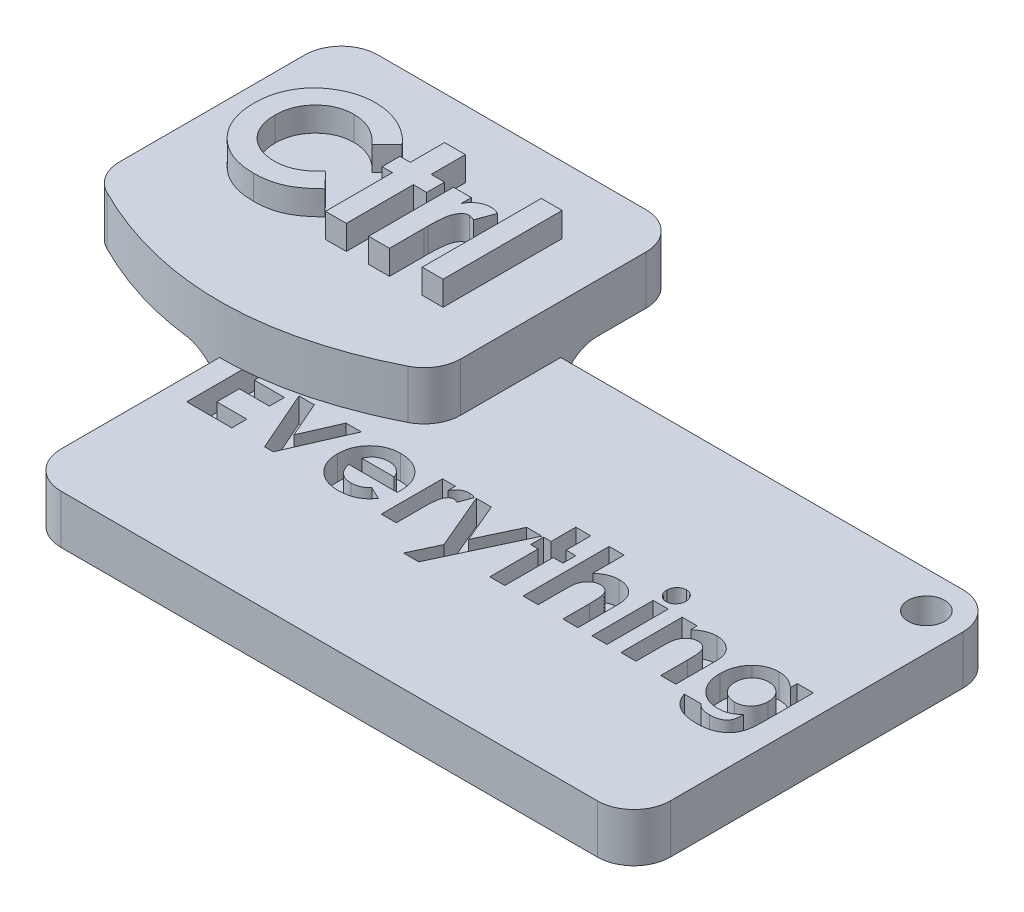
from build123d import *

# Parameters (mm, degrees)
EXTRUDE_1_DEPTH     = 4
SKETCH_2_W          = 1.709615385
SKETCH_2_H          = 9.769230769
EXTRUDE_2_DEPTH     = 2
FILLET_2_R          = 3
SKETCH_3_W          = 50
SKETCH_3_H          = 30
EXTRUDE_3_DEPTH     = 4
FILLET_3_R          = 3
SKETCH_4_W          = 1.234722222
SKETCH_4_H          = 5.027083333
CUT_EXTRUDE_1_DEPTH = 2
SKETCH_5_R          = 1.5
CUT_EXTRUDE_2_DEPTH = 59.617403706


with BuildPart() as part:
    # 草图1 → 凸台-拉伸1 (new body)
    with BuildSketch(Plane(origin=(0, 0, 0), x_dir=(1, 0, 0), z_dir=(0, 1, 0))):
        with BuildLine():
            Line((-14, -10), (-14, 10))
            Line((-14, 10), (14, 10))
            Line((14, 10), (14, -10))
            add(Edge.make_bspline(
                [(-14, -10), (0, -18), (14, -10)],
                knots=[0, 0, 0, 1, 1, 1], degree=2))
        make_face()
    extrude(amount=EXTRUDE_1_DEPTH)

    # 草图2 → 凸台-拉伸2 (add)
    with BuildSketch(Plane(origin=(0, 4, 0), x_dir=(1, 0, 0), z_dir=(0, 1, 0))):
        with BuildLine():
            Line((-1.62616058, 2.607909579), (-2.879751325, 1.409652367))
            add(Edge.make_bspline(
                [(-2.879751325, 1.409652367), (-2.986091104, 1.519607878), (-3.19380601, 1.734385438), (-3.52851289, 2.018731999), (-3.876595859, 2.255696385), (-4.231283657, 2.455266282), (-4.59895609, 2.606255132), (-4.975361862, 2.716283251), (-5.362904436, 2.783363236), (-5.625178343, 2.791038373), (-5.757095075, 2.794898761)],
                knots=[0, 0, 0, 0, 1.115251505, 2.178435587, 3.19620269, 4.182487026, 5.141301733, 6.088180966, 7.038406374, 8, 8, 8, 8], degree=3))
            add(Edge.make_bspline(
                [(-5.757095075, 2.794898761), (-5.867261576, 2.79184892), (-6.08466303, 2.785830394), (-6.403865333, 2.741708661), (-6.709198833, 2.666677735), (-7.001708734, 2.563271219), (-7.280534314, 2.429468677), (-7.546260165, 2.265373667), (-7.798231151, 2.072468201), (-8.033118881, 1.85175038), (-8.247985921, 1.610599575), (-8.437834633, 1.353292241), (-8.596863382, 1.080417855), (-8.72737569, 0.794739889), (-8.829039733, 0.494936082), (-8.901640632, 0.181208276), (-8.943631052, -0.146817156), (-8.949898404, -0.369806401), (-8.953083656, -0.483136094)],
                knots=[0, 0, 0, 0, 1.035432265, 2.043311493, 3.022114605, 3.98653278, 4.95457646, 5.923598177, 6.917315552, 7.932509744, 8.948865224, 9.949768934, 10.933144597, 11.912367597, 12.897413939, 13.903909035, 14.934704909, 16, 16, 16, 16], degree=3))
            add(Edge.make_bspline(
                [(-8.953083656, -0.483136094), (-8.952165703, -0.562678803), (-8.950356398, -0.719459116), (-8.930550354, -0.951380712), (-8.898657954, -1.176399488), (-8.852501749, -1.394174602), (-8.79478296, -1.60489478), (-8.727065679, -1.810377893), (-8.642115346, -2.007784627), (-8.547819195, -2.199407735), (-8.438153857, -2.380018539), (-8.319914393, -2.55224593), (-8.191702999, -2.715245666), (-8.052689241, -2.8683514), (-7.900916675, -3.009170432), (-7.74030806, -3.141937357), (-7.56815415, -3.263328571), (-7.388031019, -3.376390518), (-7.198382631, -3.474608393), (-7.004354585, -3.563574814), (-6.803005025, -3.635828774), (-6.596785505, -3.694072058), (-6.386432978, -3.743599272), (-6.169890003, -3.7740947), (-5.949033735, -3.797188531), (-5.799771969, -3.79861444), (-5.724658176, -3.799332008)],
                knots=[0, 0, 0, 0, 1.103660481, 2.175337485, 3.227646561, 4.255952547, 5.262355991, 6.258840057, 7.255597736, 8.242457506, 9.22035537, 10.185017736, 11.140346927, 12.096287581, 13.051739095, 14.01125915, 14.986044842, 15.97314143, 16.960198552, 17.947847494, 18.933482797, 19.925264591, 20.920966487, 21.929612487, 22.958107872, 24, 24, 24, 24], degree=3))
            add(Edge.make_bspline(
                [(-5.724658176, -3.799332008), (-5.597252274, -3.795646753), (-5.346932807, -3.788406186), (-4.979552998, -3.731785974), (-4.629476639, -3.638648931), (-4.349767303, -3.528659494), (-4.130622427, -3.420043497), (-3.963790673, -3.319579049), (-3.791273636, -3.207198534), (-3.615936677, -3.078660588), (-3.435807602, -2.93550772), (-3.254066107, -2.774604614), (-3.066059575, -2.601249578), (-2.94289836, -2.477522683), (-2.879751325, -2.414085614)],
                knots=[0, 0, 0, 0, 1.404581149, 2.759636711, 4.088442092, 5.392261763, 6.066678138, 6.783632037, 7.538459478, 8.336747902, 9.180226004, 10.074962426, 11.012997595, 12, 12, 12, 12], degree=3))
            Line((-2.879751325, -2.414085614), (-1.664321637, -3.690572993))
            add(Edge.make_bspline(
                [(-1.664321637, -3.690572993), (-1.749759802, -3.773060859), (-1.916516828, -3.934059533), (-2.168065173, -4.162662626), (-2.419296935, -4.368087918), (-2.664142876, -4.557791447), (-2.906613831, -4.726246688), (-3.146684084, -4.873621879), (-3.381635935, -5.003644352), (-3.616348235, -5.114121342), (-3.852281486, -5.207927781), (-4.095029075, -5.288688967), (-4.345333104, -5.357010026), (-4.604722317, -5.412136147), (-4.870777289, -5.456339854), (-5.14598794, -5.486177101), (-5.4286093, -5.506235689), (-5.620315747, -5.50803812), (-5.717025964, -5.508947393)],
                knots=[0, 0, 0, 0, 1.244526981, 2.429050516, 3.560637417, 4.644440555, 5.67424972, 6.652764056, 7.595344123, 8.486817594, 9.369275933, 10.254498637, 11.166417451, 12.086725134, 13.032340136, 13.991389299, 14.986715468, 16, 16, 16, 16], degree=3))
            add(Edge.make_bspline(
                [(-5.717025964, -5.508947393), (-5.894670654, -5.504418875), (-6.242271932, -5.495557825), (-6.751672543, -5.429903446), (-7.235589449, -5.319835035), (-7.695199929, -5.164167943), (-8.130357839, -4.965310528), (-8.540951851, -4.721520675), (-8.92632018, -4.433446096), (-9.283349807, -4.104463303), (-9.606300097, -3.741129426), (-9.891750754, -3.351008519), (-10.127875548, -2.932183281), (-10.323935052, -2.490841099), (-10.477251006, -2.024967957), (-10.585159446, -1.534059921), (-10.651705794, -1.018590995), (-10.658986059, -0.666513835), (-10.662699041, -0.4869522)],
                knots=[0, 0, 0, 0, 1.078019885, 2.10938526, 3.111377082, 4.085535484, 5.04941344, 6.010039228, 6.978205633, 7.964457913, 8.951525778, 9.924444315, 10.892603023, 11.863865945, 12.85144698, 13.863884204, 14.910567087, 16, 16, 16, 16], degree=3))
            add(Edge.make_bspline(
                [(-10.662699041, -0.4869522), (-10.661130115, -0.369843634), (-10.658020886, -0.137763077), (-10.625342605, 0.204110385), (-10.579787181, 0.537375859), (-10.507517643, 0.858572945), (-10.420403842, 1.172028759), (-10.312066386, 1.474336404), (-10.182678304, 1.766364741), (-10.036410079, 2.048602644), (-9.870938299, 2.319201152), (-9.686088156, 2.575835398), (-9.486618412, 2.82048655), (-9.267736135, 3.049908857), (-9.032621971, 3.266116692), (-8.780214407, 3.467938382), (-8.512031548, 3.658268278), (-8.227347523, 3.832198235), (-7.931692984, 3.989527126), (-7.628796912, 4.128297927), (-7.319403488, 4.24427836), (-7.004820856, 4.340479851), (-6.683719908, 4.412287461), (-6.35839258, 4.466643506), (-6.026070729, 4.497028883), (-5.802945395, 4.502003163), (-5.690313224, 4.504514146)],
                knots=[0, 0, 0, 0, 1.071919942, 2.124283339, 3.142214191, 4.149696895, 5.136002878, 6.119640489, 7.086990633, 8.058538607, 9.028339693, 9.988281803, 10.952401235, 11.916291999, 12.888973767, 13.874849856, 14.873389453, 15.898127285, 16.927174885, 17.938320013, 18.946391617, 19.950418109, 20.947802303, 21.956882652, 22.968648068, 24, 24, 24, 24], degree=3))
            add(Edge.make_bspline(
                [(-5.690313224, 4.504514146), (-5.594226433, 4.503074788), (-5.403051886, 4.500211037), (-5.118360906, 4.476338555), (-4.83594675, 4.438847064), (-4.556820549, 4.382280388), (-4.278985707, 4.315128596), (-4.006093285, 4.227202587), (-3.733838257, 4.12919248), (-3.466490538, 4.01204141), (-3.203676952, 3.884160434), (-2.951554319, 3.739074824), (-2.705889525, 3.585712984), (-2.472126354, 3.41499829), (-2.245885917, 3.233122881), (-2.028351247, 3.039238206), (-1.821431337, 2.830111638), (-1.69157989, 2.682351373), (-1.62616058, 2.607909579)],
                knots=[0, 0, 0, 0, 0.996412454, 1.982464992, 2.961075852, 3.949442424, 4.934965278, 5.923860011, 6.921385422, 7.934793307, 8.949617135, 9.951082467, 10.950285876, 11.951772932, 12.951063433, 13.960125323, 14.972308753, 16, 16, 16, 16], degree=3))
        make_face()
        Polygon((-0.03866058, 4.504514146), (1.670954805, 4.504514146), (1.670954805, 1.6958603), (2.769993267, 1.6958603), (2.769993267, 0.230475684), (1.670954805, 0.230475684), (1.670954805, -5.264716623), (-0.03866058, -5.264716623), (-0.03866058, 0.230475684), (-0.893468272, 0.230475684), (-0.893468272, 1.6958603), (-0.03866058, 1.6958603), align=None)
        with BuildLine():
            Line((3.502685574, 1.6958603), (4.96807019, 1.6958603))
            Line((4.96807019, 1.6958603), (4.96807019, 0.839144555))
            add(Edge.make_bspline(
                [(4.96807019, 0.839144555), (5.009523107, 0.915281119), (5.090544555, 1.064093192), (5.239387748, 1.26384393), (5.410384838, 1.432068428), (5.597391369, 1.572285256), (5.800974121, 1.681570505), (6.015681512, 1.759450022), (6.239676723, 1.810060917), (6.392478663, 1.815318432), (6.46970781, 1.817975684)],
                knots=[0, 0, 0, 0, 1.09866127, 2.147379032, 3.14564304, 4.131443017, 5.102343063, 6.064490016, 7.021754664, 8, 8, 8, 8], degree=3))
            add(Edge.make_bspline(
                [(6.46970781, 1.817975684), (6.525785807, 1.815349763), (6.639980634, 1.810002451), (6.814029619, 1.77891844), (6.990589825, 1.722712639), (7.106781655, 1.672106785), (7.166147113, 1.646250925)],
                knots=[0, 0, 0, 0, 0.931404136, 1.896671404, 2.925354185, 4, 4, 4, 4], degree=3))
            Line((7.166147113, 1.646250925), (6.635708411, 0.198038785))
            add(Edge.make_bspline(
                [(6.635708411, 0.198038785), (6.588294766, 0.220946766), (6.499175364, 0.264004952), (6.369789468, 0.314818047), (6.252366403, 0.345821714), (6.177922334, 0.350447733), (6.143430767, 0.352591069)],
                knots=[0, 0, 0, 0, 1.214386998, 2.282580073, 3.20428172, 4, 4, 4, 4], degree=3))
            add(Edge.make_bspline(
                [(6.143430767, 0.352591069), (6.110864019, 0.351170781), (6.046799615, 0.348376831), (5.952242348, 0.324433625), (5.863189093, 0.283144308), (5.775348378, 0.230248596), (5.695649862, 0.156719599), (5.616000574, 0.07159673), (5.545809357, -0.033498774), (5.471737266, -0.150475407), (5.40866753, -0.293654701), (5.354587172, -0.464581272), (5.30640114, -0.665232859), (5.273242571, -0.896674822), (5.241193483, -1.156667561), (5.222117079, -1.447119392), (5.207899193, -1.767111876), (5.207029865, -1.990478179), (5.2065768, -2.106889099)],
                knots=[0, 0, 0, 0, 0.544232178, 1.070598461, 1.618251235, 2.182094276, 2.777567932, 3.425210017, 4.127676488, 4.886675562, 5.738955394, 6.734782583, 7.883056018, 9.186093582, 10.642914445, 12.264202625, 14.053029461, 16, 16, 16, 16], degree=3))
            Line((5.2065768, -2.106889099), (5.212300959, -2.446522513))
            Line((5.212300959, -2.446522513), (5.212300959, -5.264716623))
            Line((5.212300959, -5.264716623), (3.502685574, -5.264716623))
            Line((3.502685574, -5.264716623), (3.502685574, 1.6958603))
        make_face()
        with Locations((8.753647113, -0.380101238)):
            Rectangle(SKETCH_2_W, SKETCH_2_H)
    extrude(amount=EXTRUDE_2_DEPTH)

    # 圆角2
    fillet_2_edges = [part.edges().sort_by_distance(p)[0] for p in [
        (14, 2, -10),
        (14, 2, 10),
        (-14, 2, 10),
        (-14, 2, -10),
    ]]
    fillet(fillet_2_edges, radius=FILLET_2_R)

    # 草图3 → 凸台-拉伸3 (add)
    with BuildSketch(Plane.XZ):
        with Locations((25, 15)):
            Rectangle(SKETCH_3_W, SKETCH_3_H)
    extrude(amount=EXTRUDE_3_DEPTH)

    # 圆角3
    fillet_3_edges = [part.edges().sort_by_distance(p)[0] for p in [
        (0, 0, 7),
        (7, 0, 0),
        (0, -2, 30),
        (50, -2, 30),
        (50, -2, 0),
    ]]
    fillet(fillet_3_edges, radius=FILLET_3_R)

    # 草图4 → 切除-拉伸1 (cut)
    with BuildSketch(Plane(origin=(0, 0, 0), x_dir=(1, 0, 0), z_dir=(0, 1, 0))):
        Polygon((1.80262527, -11.616395699), (5.506791936, -11.616395699), (5.506791936, -12.851117921), (3.037347492, -12.851117921), (3.037347492, -14.174034587), (5.506791936, -14.174034587), (5.506791936, -15.40875681), (3.037347492, -15.40875681), (3.037347492, -17.260840143), (5.506791936, -17.260840143), (5.506791936, -18.495562365), (1.80262527, -18.495562365), align=None)
        Polygon((5.991861381, -13.468479032), (7.248632214, -13.468479032), (8.54950027, -16.435395265), (9.850368325, -13.468479032), (11.107139158, -13.468479032), (8.905034124, -18.495562365), (8.193966415, -18.495562365), align=None)
        with BuildLine():
            Line((16.879741155, -16.290701254), (12.91512527, -16.290701254))
            add(Edge.make_bspline(
                [(12.91512527, -16.290701254), (12.923208801, -16.336767841), (12.939093579, -16.42729232), (12.973587938, -16.55878698), (13.017607913, -16.682705329), (13.070363081, -16.799213014), (13.130963991, -16.908925966), (13.201649931, -17.011329588), (13.281524316, -17.106333431), (13.370125332, -17.193524598), (13.465976161, -17.271649773), (13.568611964, -17.340092365), (13.678138652, -17.396211104), (13.793300544, -17.443513377), (13.914958165, -17.48098157), (14.043290563, -17.50682267), (14.177957549, -17.522087102), (14.269696814, -17.524294928), (14.316590113, -17.525423476)],
                knots=[0, 0, 0, 0, 1.091296461, 2.144483647, 3.168565212, 4.157007626, 5.126487748, 6.090021542, 7.05641414, 8.019231907, 8.98705074, 9.938580405, 10.892824166, 11.854447369, 12.841318655, 13.858982407, 14.905600794, 16, 16, 16, 16], degree=3))
            add(Edge.make_bspline(
                [(14.316590113, -17.525423476), (14.373193509, -17.523929092), (14.484662264, -17.520986209), (14.64796482, -17.49488721), (14.80590218, -17.455465818), (14.9569797, -17.396842899), (15.102947374, -17.32386767), (15.241402129, -17.232949515), (15.374740505, -17.126745358), (15.456092628, -17.044883235), (15.497568846, -17.003147001)],
                knots=[0, 0, 0, 0, 1.021034703, 2.010718019, 2.977989445, 3.954245119, 4.929443971, 5.918328161, 6.938689359, 8, 8, 8, 8], degree=3))
            Line((15.497568846, -17.003147001), (16.531097492, -17.495106636))
            add(Edge.make_bspline(
                [(16.531097492, -17.495106636), (16.498557446, -17.540071986), (16.434080541, -17.629169173), (16.328824157, -17.754551926), (16.218982419, -17.871539121), (16.104473405, -17.979361315), (15.985151891, -18.077711259), (15.8613498, -18.167787031), (15.731257814, -18.247170134), (15.5974771, -18.319701074), (15.457242163, -18.381881512), (15.310941094, -18.434906795), (15.159193561, -18.4828412), (15.00008332, -18.51936459), (14.834935282, -18.548276208), (14.663354378, -18.568807287), (14.485363224, -18.581488351), (14.364383673, -18.582991675), (14.302809731, -18.58375681)],
                knots=[0, 0, 0, 0, 1.028154879, 2.037251081, 3.030720504, 4.000128189, 4.949298328, 5.894184978, 6.834267904, 7.770992897, 8.712077017, 9.673380525, 10.653304757, 11.658697181, 12.695551717, 13.758623199, 14.859225354, 16, 16, 16, 16], degree=3))
            add(Edge.make_bspline(
                [(14.302809731, -18.58375681), (14.208079233, -18.58182554), (14.022555013, -18.578043259), (13.751192303, -18.542938281), (13.493472993, -18.484730444), (13.248669375, -18.405605829), (13.017839652, -18.301136549), (12.800869587, -18.173361953), (12.595591338, -18.024731737), (12.408277302, -17.852126548), (12.237628689, -17.664256061), (12.087741557, -17.462495986), (11.96231814, -17.248255946), (11.859317907, -17.022953826), (11.779262548, -16.786012941), (11.721547277, -16.537329894), (11.686167125, -16.277023461), (11.682345893, -16.099725722), (11.680403047, -16.009581462)],
                knots=[0, 0, 0, 0, 1.103565453, 2.161269334, 3.182010356, 4.179077853, 5.15417608, 6.128274628, 7.109042802, 8.101804412, 9.090965879, 10.063106201, 11.02526161, 11.978650795, 12.945248442, 13.93468508, 14.949922959, 16, 16, 16, 16], degree=3))
            add(Edge.make_bspline(
                [(11.680403047, -16.009581462), (11.682365015, -15.917146521), (11.686225097, -15.735284926), (11.721242654, -15.468967899), (11.779422111, -15.214865433), (11.859711649, -14.972627605), (11.961149356, -14.741496796), (12.088168571, -14.523495126), (12.237554308, -14.31786363), (12.407588163, -14.125564274), (12.595695719, -13.951993096), (12.79557777, -13.79730649), (13.009480194, -13.668411342), (13.234983572, -13.564264142), (13.470645502, -13.479647171), (13.719189907, -13.423341644), (13.978725743, -13.385535853), (14.156138725, -13.382054175), (14.246310165, -13.380284587)],
                knots=[0, 0, 0, 0, 1.079208495, 2.12329425, 3.130605359, 4.119693003, 5.099659317, 6.073216462, 7.060498243, 8.06384408, 9.066070512, 10.045757761, 11.010926815, 11.975797609, 12.942977511, 13.929384301, 14.947594487, 16, 16, 16, 16], degree=3))
            add(Edge.make_bspline(
                [(14.246310165, -13.380284587), (14.341494487, -13.38224582), (14.528379092, -13.386096497), (14.80163176, -13.42091643), (15.061062295, -13.479479212), (15.307776015, -13.557919651), (15.538622287, -13.665027935), (15.758673502, -13.7896582), (15.962651583, -13.941501171), (16.152730721, -14.113261686), (16.324315991, -14.303824025), (16.474300528, -14.510833091), (16.60191891, -14.732268596), (16.705354874, -14.969028508), (16.785328031, -15.220402051), (16.843096728, -15.486062768), (16.878207014, -15.767021103), (16.881957141, -15.959409378), (16.88387527, -16.057812799)],
                knots=[0, 0, 0, 0, 1.080001299, 2.120471247, 3.119684163, 4.095710327, 5.052285597, 6.002875087, 6.961153713, 7.931888285, 8.906493152, 9.865905668, 10.82813294, 11.801621613, 12.7925306, 13.817193356, 14.883530496, 16, 16, 16, 16], degree=3))
            Line((16.88387527, -16.057812799), (16.879741155, -16.290701254))
        make_face()
        with BuildLine():
            add(Edge.make_bspline(
                [(15.649153047, -15.320562365), (15.625853084, -15.257685202), (15.579526687, -15.132669022), (15.474877284, -14.960177198), (15.336010874, -14.810792273), (15.174499278, -14.678540614), (14.989962165, -14.571196907), (14.788214625, -14.493476577), (14.571806707, -14.446874492), (14.42292972, -14.441408886), (14.346906954, -14.438617921)],
                knots=[0, 0, 0, 0, 0.954238005, 1.897273737, 2.851915805, 3.847685534, 4.862635127, 5.880135777, 6.917509367, 8, 8, 8, 8], degree=3))
            add(Edge.make_bspline(
                [(14.346906954, -14.438617921), (14.263877715, -14.441298983), (14.101572841, -14.4465399), (13.867459112, -14.502278983), (13.646625489, -14.585467899), (13.516434501, -14.671237438), (13.451182127, -14.71422556)],
                knots=[0, 0, 0, 0, 1.044195649, 2.041185066, 3.018232172, 4, 4, 4, 4], degree=3))
            add(Edge.make_bspline(
                [(13.451182127, -14.71422556), (13.41046952, -14.746966254), (13.323672321, -14.816767742), (13.21094855, -14.956015083), (13.099914698, -15.124612354), (13.036785831, -15.252673892), (13.003319714, -15.320562365)],
                knots=[0, 0, 0, 0, 0.82159062, 1.751589201, 2.808063854, 4, 4, 4, 4], degree=3))
            Line((13.003319714, -15.320562365), (15.649153047, -15.320562365))
        make_face(mode=Mode.SUBTRACT)
        with BuildLine():
            Line((17.765819714, -13.468479032), (18.824153047, -13.468479032))
            Line((18.824153047, -13.468479032), (18.824153047, -14.087218181))
            add(Edge.make_bspline(
                [(18.824153047, -14.087218181), (18.854091266, -14.032230663), (18.912606755, -13.924755277), (19.020104617, -13.780490855), (19.143602515, -13.658995383), (19.278662788, -13.557727675), (19.425694776, -13.478799439), (19.580761225, -13.422553121), (19.742535544, -13.386000809), (19.8528925, -13.382203714), (19.908669106, -13.380284587)],
                knots=[0, 0, 0, 0, 1.09866127, 2.147379032, 3.14564304, 4.131443017, 5.102343063, 6.064490016, 7.021754664, 8, 8, 8, 8], degree=3))
            add(Edge.make_bspline(
                [(19.908669106, -13.380284587), (19.949169882, -13.382181086), (20.031643924, -13.386043034), (20.157345968, -13.408492597), (20.284861673, -13.449085676), (20.368777995, -13.485634348), (20.411653047, -13.504308025)],
                knots=[0, 0, 0, 0, 0.931404136, 1.896671404, 2.925354185, 4, 4, 4, 4], degree=3))
            Line((20.411653047, -13.504308025), (20.028558429, -14.550239015))
            add(Edge.make_bspline(
                [(20.028558429, -14.550239015), (19.994315241, -14.533694362), (19.929951229, -14.502596783), (19.83650586, -14.465898437), (19.751700312, -14.443506899), (19.697935152, -14.440165886), (19.673024575, -14.438617921)],
                knots=[0, 0, 0, 0, 1.214386998, 2.282580073, 3.20428172, 4, 4, 4, 4], degree=3))
            add(Edge.make_bspline(
                [(19.673024575, -14.438617921), (19.649504146, -14.439643684), (19.60323541, -14.441661537), (19.534944051, -14.458953853), (19.470627811, -14.488773915), (19.407187294, -14.526976374), (19.349627255, -14.580080649), (19.292102769, -14.641558277), (19.241409112, -14.717460585), (19.187912603, -14.801943709), (19.142362237, -14.905350977), (19.103304202, -15.028797945), (19.068503178, -15.17371298), (19.044555323, -15.340865509), (19.021408759, -15.528638043), (19.007631356, -15.738408809), (18.997362883, -15.969514492), (18.996735035, -16.1308346), (18.996407822, -16.214909153)],
                knots=[0, 0, 0, 0, 0.544232178, 1.070598461, 1.618251235, 2.182094276, 2.777567932, 3.425210017, 4.127676488, 4.886675562, 5.738955394, 6.734782583, 7.883056018, 9.186093582, 10.642914445, 12.264202625, 14.053029461, 16, 16, 16, 16], degree=3))
            Line((18.996407822, -16.214909153), (19.000541936, -16.460199952))
            Line((19.000541936, -16.460199952), (19.000541936, -18.495562365))
            Line((19.000541936, -18.495562365), (17.765819714, -18.495562365))
            Line((17.765819714, -18.495562365), (17.765819714, -13.468479032))
        make_face()
        Polygon((20.541188638, -13.468479032), (21.777288898, -13.468479032), (23.14981494, -16.702734674), (24.66841303, -13.468479032), (25.923805825, -13.468479032), (22.692306259, -20.347645699), (21.436913464, -20.347645699), (22.499380912, -18.086285021), align=None)
        Polygon((26.673458603, -11.44000681), (27.908180825, -11.44000681), (27.908180825, -13.468479032), (28.701930825, -13.468479032), (28.701930825, -14.526812365), (27.908180825, -14.526812365), (27.908180825, -18.495562365), (26.673458603, -18.495562365), (26.673458603, -14.526812365), (26.056097492, -14.526812365), (26.056097492, -13.468479032), (26.673458603, -13.468479032), align=None)
        with BuildLine():
            Line((29.407486381, -11.44000681), (30.642208603, -11.44000681))
            Line((30.642208603, -11.44000681), (30.642208603, -14.012804119))
            add(Edge.make_bspline(
                [(30.642208603, -14.012804119), (30.704404178, -13.962223003), (30.825634132, -13.863631644), (31.015847904, -13.735190497), (31.205668242, -13.625586015), (31.397109419, -13.536759076), (31.589340895, -13.467150606), (31.782694622, -13.417785441), (31.977356738, -13.385397535), (32.107855311, -13.381990721), (32.173209037, -13.380284587)],
                knots=[0, 0, 0, 0, 1.13710654, 2.216417683, 3.252896077, 4.244436563, 5.207303112, 6.149540546, 7.073289332, 8, 8, 8, 8], degree=3))
            add(Edge.make_bspline(
                [(32.173209037, -13.380284587), (32.235748166, -13.381944012), (32.358517729, -13.385201601), (32.53862812, -13.408731629), (32.711137907, -13.44922074), (32.876472059, -13.504880044), (33.033493109, -13.579733608), (33.18424294, -13.667415107), (33.32692969, -13.772465743), (33.41374645, -13.853443898), (33.457540634, -13.894292834)],
                knots=[0, 0, 0, 0, 1.056403236, 2.073808271, 3.062028718, 4.046096703, 5.014652014, 5.995532726, 6.988858718, 8, 8, 8, 8], degree=3))
            add(Edge.make_bspline(
                [(33.457540634, -13.894292834), (33.49350722, -13.932462423), (33.565962232, -14.009355405), (33.656203016, -14.141917129), (33.734125032, -14.286309742), (33.797620365, -14.443890089), (33.844842821, -14.614731523), (33.881402578, -14.797426628), (33.901620901, -14.993970225), (33.904116122, -15.129430514), (33.905403047, -15.199295004)],
                knots=[0, 0, 0, 0, 0.887296576, 1.787466942, 2.706642908, 3.663267187, 4.658426068, 5.705361056, 6.816525637, 8, 8, 8, 8], degree=3))
            Line((33.905403047, -15.199295004), (33.905403047, -18.495562365))
            Line((33.905403047, -18.495562365), (32.670680825, -18.495562365))
            Line((32.670680825, -18.495562365), (32.670680825, -16.309993789))
            add(Edge.make_bspline(
                [(32.670680825, -16.309993789), (32.670440916, -16.24063044), (32.669981705, -16.107861835), (32.665857982, -15.917202633), (32.659123813, -15.743996037), (32.64991453, -15.588189703), (32.637056358, -15.450434772), (32.624409442, -15.329743869), (32.606662856, -15.226695509), (32.580089593, -15.114723672), (32.536843957, -14.994960757), (32.474001009, -14.867298637), (32.390060098, -14.76193815), (32.292919252, -14.675042164), (32.180601727, -14.60871986), (32.057128381, -14.559735358), (31.920388368, -14.532187685), (31.825606345, -14.528650938), (31.776334037, -14.526812365)],
                knots=[0, 0, 0, 0, 1.461461505, 2.797388094, 4.017818807, 5.113567707, 6.085313608, 6.932873269, 7.669572396, 8.286941306, 9.355291607, 10.346554054, 11.270113241, 12.175128673, 13.078071705, 14.003657132, 14.962203834, 16, 16, 16, 16], degree=3))
            add(Edge.make_bspline(
                [(31.776334037, -14.526812365), (31.712146817, -14.529321655), (31.586428912, -14.534236382), (31.406143874, -14.584827619), (31.239854643, -14.664793491), (31.089501972, -14.77562259), (30.958485574, -14.914440452), (30.848714052, -15.077148849), (30.758926956, -15.262120344), (30.720119358, -15.397004757), (30.700086207, -15.466634414)],
                knots=[0, 0, 0, 0, 0.993549393, 1.945978497, 2.879753144, 3.843180486, 4.826017097, 5.826060929, 6.877775219, 8, 8, 8, 8], degree=3))
            add(Edge.make_bspline(
                [(30.700086207, -15.466634414), (30.69509791, -15.488155928), (30.68372296, -15.537232022), (30.675011808, -15.620964267), (30.662084596, -15.722182204), (30.657600354, -15.841492385), (30.649200306, -15.978710786), (30.646179318, -16.134059417), (30.643137951, -16.307684328), (30.642528344, -16.429421379), (30.642208603, -16.493272869)],
                knots=[0, 0, 0, 0, 0.514379255, 1.17295301, 1.959069106, 2.891908278, 3.953016936, 5.163065833, 6.51201855, 8, 8, 8, 8], degree=3))
            Line((30.642208603, -16.493272869), (30.642208603, -18.495562365))
            Line((30.642208603, -18.495562365), (29.407486381, -18.495562365))
            Line((29.407486381, -18.495562365), (29.407486381, -11.44000681))
        make_face()
        with BuildLine():
            add(Edge.make_bspline(
                [(35.66653586, -11.351812365), (35.719752379, -11.354423369), (35.824248141, -11.359550327), (35.973952541, -11.409526758), (36.11135084, -11.487963275), (36.232814746, -11.595580044), (36.333837066, -11.724094151), (36.41102187, -11.867974238), (36.454018309, -12.02738874), (36.459989878, -12.137510611), (36.463041936, -12.193793702)],
                knots=[0, 0, 0, 0, 0.989868614, 1.943702388, 2.910836514, 3.924849579, 4.949916355, 5.946401046, 6.950409252, 8, 8, 8, 8], degree=3))
            add(Edge.make_bspline(
                [(36.463041936, -12.193793702), (36.460099075, -12.249662018), (36.454364771, -12.358524091), (36.41003228, -12.515774467), (36.335945406, -12.659584671), (36.234104869, -12.786190105), (36.11395779, -12.892073643), (35.979561749, -12.971934127), (35.831291952, -13.019130381), (35.728417648, -13.024685924), (35.676182127, -13.02750681)],
                knots=[0, 0, 0, 0, 1.05296456, 2.051751585, 3.055639087, 4.085634717, 5.099016424, 6.062201612, 7.016062274, 8, 8, 8, 8], degree=3))
            add(Edge.make_bspline(
                [(35.676182127, -13.02750681), (35.622501072, -13.02490514), (35.517096201, -13.019796658), (35.366163917, -12.969703293), (35.226933076, -12.891884515), (35.105996079, -12.782068968), (35.003816828, -12.652641671), (34.930003487, -12.505411931), (34.883831416, -12.344907356), (34.878350832, -12.233154506), (34.875541936, -12.175879206)],
                knots=[0, 0, 0, 0, 0.989065327, 1.942068821, 2.907541208, 3.917690034, 4.939857478, 5.938239964, 6.943311734, 8, 8, 8, 8], degree=3))
            add(Edge.make_bspline(
                [(34.875541936, -12.175879206), (34.878598783, -12.120959567), (34.884603516, -12.013077866), (34.927857509, -11.857207616), (35.003272468, -11.715746378), (35.103567114, -11.589584842), (35.223964158, -11.48397553), (35.361279975, -11.407921182), (35.509976858, -11.360008919), (35.613810677, -11.354572761), (35.66653586, -11.351812365)],
                knots=[0, 0, 0, 0, 1.038616768, 2.040212704, 3.031499824, 4.052181184, 5.074969369, 6.039807101, 7.004644834, 8, 8, 8, 8], degree=3))
        make_face()
        with Locations((35.669291936, -15.982020699)):
            Rectangle(SKETCH_4_W, SKETCH_4_H)
        with BuildLine():
            Line((37.433180825, -13.468479032), (38.667903047, -13.468479032))
            Line((38.667903047, -13.468479032), (38.667903047, -14.000401775))
            add(Edge.make_bspline(
                [(38.667903047, -14.000401775), (38.738343338, -13.945611866), (38.872968427, -13.840897699), (39.077621806, -13.707386603), (39.270789257, -13.598113132), (39.456776691, -13.514994138), (39.639083465, -13.455193596), (39.820662169, -13.412230474), (40.004216878, -13.384720006), (40.127610197, -13.381762267), (40.189257214, -13.380284587)],
                knots=[0, 0, 0, 0, 1.276643801, 2.439914479, 3.493451431, 4.44993799, 5.350072675, 6.235028322, 7.118224225, 8, 8, 8, 8], degree=3))
            add(Edge.make_bspline(
                [(40.189257214, -13.380284587), (40.251789817, -13.381973269), (40.374546569, -13.385288293), (40.555299122, -13.408474201), (40.727990633, -13.450703084), (40.894562875, -13.506771619), (41.053320427, -13.58077887), (41.206208168, -13.668650473), (41.349942121, -13.775684031), (41.438459853, -13.85719565), (41.483235079, -13.898426949)],
                knots=[0, 0, 0, 0, 1.048836932, 2.058954983, 3.049370783, 4.026390553, 5.001981509, 5.982488534, 6.97947532, 8, 8, 8, 8], degree=3))
            add(Edge.make_bspline(
                [(41.483235079, -13.898426949), (41.519146457, -13.936636306), (41.591232043, -14.013334668), (41.681942696, -14.144585209), (41.75978264, -14.287672322), (41.823561658, -14.444246564), (41.870691782, -14.615168209), (41.90694963, -14.798372767), (41.927294541, -14.994886049), (41.929806216, -15.129888819), (41.931097492, -15.199295004)],
                knots=[0, 0, 0, 0, 0.889584746, 1.785680191, 2.700364693, 3.65222533, 4.649950538, 5.707241244, 6.821271309, 8, 8, 8, 8], degree=3))
            Line((41.931097492, -15.199295004), (41.931097492, -18.495562365))
            Line((41.931097492, -18.495562365), (40.69637527, -18.495562365))
            Line((40.69637527, -18.495562365), (40.69637527, -16.312749865))
            add(Edge.make_bspline(
                [(40.69637527, -16.312749865), (40.696114153, -16.241550324), (40.695613772, -16.105109619), (40.691771951, -15.909842464), (40.684270478, -15.733490866), (40.677433081, -15.575733738), (40.664008553, -15.437131225), (40.651902096, -15.316805866), (40.633325912, -15.215849263), (40.609155283, -15.107255288), (40.566947412, -14.99098558), (40.50142175, -14.868476234), (40.418293259, -14.764401813), (40.320957238, -14.678032705), (40.209521188, -14.609706818), (40.08533165, -14.5616353), (39.94905443, -14.53167595), (39.854098064, -14.528474808), (39.804784558, -14.526812365)],
                knots=[0, 0, 0, 0, 1.49886392, 2.872294502, 4.110984203, 5.214877267, 6.195405875, 7.042225351, 7.75923308, 8.355011229, 9.382752534, 10.352059385, 11.267231453, 12.171456522, 13.078624015, 14.003401117, 14.963110155, 16, 16, 16, 16], degree=3))
            add(Edge.make_bspline(
                [(39.804784558, -14.526812365), (39.740650269, -14.530064632), (39.615191131, -14.536426699), (39.433739588, -14.584402484), (39.267079368, -14.665995172), (39.116572224, -14.778903045), (38.98365161, -14.918301806), (38.874174665, -15.08455082), (38.78438108, -15.273637675), (38.745768504, -15.411701793), (38.725780651, -15.483170872)],
                knots=[0, 0, 0, 0, 0.984188326, 1.925263693, 2.85911992, 3.81709677, 4.80007086, 5.801799564, 6.862098548, 8, 8, 8, 8], degree=3))
            add(Edge.make_bspline(
                [(38.725780651, -15.483170872), (38.720812876, -15.505616215), (38.709733738, -15.555673843), (38.700622548, -15.640240734), (38.687948222, -15.740571162), (38.683199464, -15.858480826), (38.674941896, -15.993411708), (38.671887852, -16.145542319), (38.668828344, -16.314574356), (38.668221698, -16.432636812), (38.667903047, -16.494650907)],
                knots=[0, 0, 0, 0, 0.543362196, 1.211806945, 2.009705693, 2.934833164, 4.000995085, 5.207458376, 6.533175157, 8, 8, 8, 8], degree=3))
            Line((38.667903047, -16.494650907), (38.667903047, -18.495562365))
            Line((38.667903047, -18.495562365), (37.433180825, -18.495562365))
            Line((37.433180825, -18.495562365), (37.433180825, -13.468479032))
        make_face()
        with BuildLine():
            Line((46.869986381, -13.468479032), (48.192903047, -13.468479032))
            Line((48.192903047, -13.468479032), (48.192903047, -17.756933893))
            add(Edge.make_bspline(
                [(48.192903047, -17.756933893), (48.191313246, -17.859414306), (48.188243278, -18.057308009), (48.164824681, -18.344107099), (48.125771152, -18.60998563), (48.069574503, -18.855320149), (47.996993829, -19.079208935), (47.908224911, -19.282396308), (47.805072605, -19.465971906), (47.72025845, -19.573239533), (47.678894801, -19.625553685)],
                knots=[0, 0, 0, 0, 1.243822755, 2.401870584, 3.490053692, 4.503076575, 5.453444971, 6.342269266, 7.191528908, 8, 8, 8, 8], degree=3))
            add(Edge.make_bspline(
                [(47.678894801, -19.625553685), (47.619496029, -19.690707364), (47.500999209, -19.820684863), (47.292082671, -19.984711869), (47.063206909, -20.124902803), (46.812036205, -20.239795994), (46.538869732, -20.327307952), (46.244409228, -20.390332158), (45.928468014, -20.429586603), (45.71025587, -20.433716607), (45.598057127, -20.435840143)],
                knots=[0, 0, 0, 0, 0.916003385, 1.827369254, 2.751972866, 3.703651841, 4.69362366, 5.730423306, 6.83304546, 8, 8, 8, 8], degree=3))
            add(Edge.make_bspline(
                [(45.598057127, -20.435840143), (45.479456565, -20.434004063), (45.251357144, -20.430472809), (44.92358298, -20.39592905), (44.6250123, -20.339089678), (44.354243022, -20.259067897), (44.10875253, -20.155816657), (43.883911493, -20.032012463), (43.680151714, -19.883994359), (43.494393267, -19.717597747), (43.330944241, -19.529168472), (43.191374809, -19.320431735), (43.072468908, -19.093307495), (43.013757768, -18.930887683), (42.983918672, -18.848340143)],
                knots=[0, 0, 0, 0, 1.29412125, 2.488928388, 3.592140377, 4.607309753, 5.564519828, 6.493640275, 7.402258018, 8.307438948, 9.210158992, 10.116782752, 11.042881838, 12, 12, 12, 12], degree=3))
            Line((42.983918672, -18.848340143), (44.356444714, -18.848340143))
            add(Edge.make_bspline(
                [(44.356444714, -18.848340143), (44.388162324, -18.883258208), (44.452000612, -18.953538079), (44.564913147, -19.042718474), (44.689820004, -19.119052544), (44.827728926, -19.181557846), (44.979214932, -19.229087523), (45.143246832, -19.265197314), (45.320559361, -19.285547072), (45.442747434, -19.288031686), (45.505728568, -19.289312365)],
                knots=[0, 0, 0, 0, 0.888971165, 1.789239437, 2.70354581, 3.646217955, 4.638595249, 5.694475788, 6.811630907, 8, 8, 8, 8], degree=3))
            add(Edge.make_bspline(
                [(45.505728568, -19.289312365), (45.585320161, -19.287825242), (45.737333126, -19.284984966), (45.952397939, -19.253929639), (46.144455035, -19.207534796), (46.310731974, -19.137711689), (46.454187188, -19.053844532), (46.573863769, -18.956421923), (46.672681819, -18.849114282), (46.737319163, -18.748164009), (46.775729078, -18.656585744), (46.80188394, -18.57750923), (46.821746223, -18.486359196), (46.83982614, -18.384841639), (46.853341172, -18.271648676), (46.862295055, -18.147020106), (46.870059414, -18.011505017), (46.870011263, -17.917258435), (46.869986381, -17.868554987)],
                knots=[0, 0, 0, 0, 1.656375485, 3.163532, 4.516250129, 5.759907703, 6.905105653, 7.965920022, 8.961443813, 9.932912751, 10.442911961, 11.026787936, 11.664959534, 12.383728702, 13.174001396, 14.037595414, 14.985895623, 16, 16, 16, 16], degree=3))
            add(Edge.make_bspline(
                [(46.869986381, -17.868554987), (46.815893576, -17.921608439), (46.710337238, -18.025136592), (46.538983015, -18.157216227), (46.363571625, -18.266310753), (46.183095004, -18.353036124), (45.993963886, -18.416560929), (45.795067431, -18.462184798), (45.584140461, -18.489984149), (45.439208392, -18.493676234), (45.365168672, -18.495562365)],
                knots=[0, 0, 0, 0, 1.082007397, 2.111422008, 3.08419067, 4.02964304, 4.965866572, 5.929243163, 6.942137121, 8, 8, 8, 8], degree=3))
            add(Edge.make_bspline(
                [(45.365168672, -18.495562365), (45.283272126, -18.4936704), (45.122398265, -18.489953909), (44.88610767, -18.453836881), (44.659407857, -18.397642309), (44.44168839, -18.31941421), (44.235170857, -18.215554965), (44.036916438, -18.091991433), (43.850599364, -17.942235393), (43.673649171, -17.774646714), (43.513717516, -17.588364563), (43.37298755, -17.388297785), (43.254348659, -17.175826436), (43.157868002, -16.951148032), (43.080997582, -16.715205762), (43.028094369, -16.466722291), (42.995766395, -16.206117173), (42.991570759, -16.028509926), (42.989430825, -15.937923476)],
                knots=[0, 0, 0, 0, 1.007560175, 1.979205489, 2.935124557, 3.879618859, 4.820364716, 5.775815361, 6.749909327, 7.75781854, 8.772289371, 9.766897274, 10.764314289, 11.762244114, 12.772609037, 13.814079916, 14.885097635, 16, 16, 16, 16], degree=3))
            add(Edge.make_bspline(
                [(42.989430825, -15.937923476), (42.991299845, -15.84134605), (42.994952612, -15.652597507), (43.03076015, -15.376906157), (43.086478412, -15.115075503), (43.166017695, -14.867653239), (43.270514463, -14.635697082), (43.396794627, -14.418471013), (43.543666953, -14.213490969), (43.659928667, -14.091889228), (43.71841303, -14.030718615)],
                knots=[0, 0, 0, 0, 1.104124469, 2.157873671, 3.173961494, 4.162551312, 5.124378318, 6.07778831, 7.033049473, 8, 8, 8, 8], degree=3))
            add(Edge.make_bspline(
                [(43.71841303, -14.030718615), (43.773913847, -13.978559864), (43.883280979, -13.87577844), (44.062314633, -13.743892814), (44.247734668, -13.630774349), (44.442084322, -13.539783297), (44.643988378, -13.467323004), (44.854642127, -13.416631278), (45.072998141, -13.38537593), (45.221288435, -13.381994368), (45.296266763, -13.380284587)],
                knots=[0, 0, 0, 0, 1.042068658, 2.053448347, 3.038272799, 4.011764631, 4.986555969, 5.970496305, 6.973845226, 8, 8, 8, 8], degree=3))
            add(Edge.make_bspline(
                [(45.296266763, -13.380284587), (45.366625437, -13.382260235), (45.506045608, -13.386175105), (45.712605728, -13.413796166), (45.912623218, -13.462592781), (46.10828813, -13.529677867), (46.301674353, -13.616578958), (46.492614772, -13.730479576), (46.684980643, -13.866672526), (46.807043509, -13.97308826), (46.869986381, -14.027962539)],
                knots=[0, 0, 0, 0, 0.968122651, 1.918396369, 2.861262201, 3.796768263, 4.761417965, 5.77287463, 6.85156174, 8, 8, 8, 8], degree=3))
            Line((46.869986381, -14.027962539), (46.869986381, -13.468479032))
        make_face()
        with BuildLine():
            add(Edge.make_bspline(
                [(45.591166936, -14.526812365), (45.542895102, -14.528367847), (45.447860304, -14.531430191), (45.30818915, -14.548683735), (45.175640581, -14.581251458), (45.048599138, -14.623539506), (44.928609429, -14.680425306), (44.815439491, -14.749830539), (44.707747903, -14.830390862), (44.60896147, -14.923626474), (44.517393221, -15.024369685), (44.440509323, -15.135243333), (44.371992065, -15.249934091), (44.318709732, -15.373057059), (44.274649916, -15.50127094), (44.247722376, -15.637184822), (44.226206439, -15.778314458), (44.224846401, -15.874902228), (44.224153047, -15.924143094)],
                knots=[0, 0, 0, 0, 1.059154978, 2.085203149, 3.079850876, 4.048488546, 5.017545358, 5.985239295, 6.956545898, 7.961752598, 8.960830395, 9.936516972, 10.916356752, 11.886198968, 12.873933111, 13.883774911, 14.921139228, 16, 16, 16, 16], degree=3))
            add(Edge.make_bspline(
                [(44.224153047, -15.924143094), (44.224903575, -15.97520656), (44.226376577, -16.075424902), (44.246999958, -16.221424307), (44.276460155, -16.361154525), (44.320962208, -16.492909892), (44.376674669, -16.618421603), (44.443598268, -16.737627982), (44.52621171, -16.847678858), (44.617951119, -16.95099613), (44.719439692, -17.044406764), (44.828683163, -17.125653944), (44.943432409, -17.195819246), (45.066167933, -17.250525901), (45.194234121, -17.294857263), (45.328915449, -17.327050691), (45.469902416, -17.344444618), (45.56585913, -17.347488608), (45.614593586, -17.349034587)],
                knots=[0, 0, 0, 0, 1.097915424, 2.154794285, 3.166904039, 4.167166757, 5.140698173, 6.119085138, 7.101657521, 8.095747232, 9.089148684, 10.06378348, 11.021581144, 11.977080764, 12.949256321, 13.934658686, 14.951055324, 16, 16, 16, 16], degree=3))
            add(Edge.make_bspline(
                [(45.614593586, -17.349034587), (45.662444963, -17.348284316), (45.756266391, -17.346813271), (45.893125325, -17.326177385), (46.023882774, -17.29633964), (46.148303247, -17.253671593), (46.26569624, -17.19798053), (46.377637031, -17.131521691), (46.481751134, -17.051098935), (46.580013093, -16.960175475), (46.668688238, -16.859070996), (46.746958707, -16.749525618), (46.811255062, -16.631519561), (46.866022404, -16.506921114), (46.906572257, -16.373972668), (46.937360951, -16.233994424), (46.95542142, -16.086308266), (46.957249151, -15.985285239), (46.958180825, -15.933789362)],
                knots=[0, 0, 0, 0, 1.047368431, 2.053558439, 3.025081491, 3.983010266, 4.928381778, 5.867249904, 6.829345556, 7.804873619, 8.796055618, 9.770545002, 10.747991713, 11.735078325, 12.747239243, 13.787476531, 14.872179528, 16, 16, 16, 16], degree=3))
            add(Edge.make_bspline(
                [(46.958180825, -15.933789362), (46.95727693, -15.882748348), (46.955512029, -15.783088208), (46.937196521, -15.637278553), (46.906675399, -15.499056135), (46.865563865, -15.367280194), (46.811986333, -15.242737669), (46.744800344, -15.126587708), (46.667970312, -15.016685553), (46.577505614, -14.916774763), (46.479998077, -14.824366641), (46.372498448, -14.746191343), (46.260382834, -14.677118471), (46.139865783, -14.622359942), (46.012444243, -14.579230716), (45.877913562, -14.549727871), (45.736959844, -14.529025294), (45.640395738, -14.527559588), (45.591166936, -14.526812365)],
                knots=[0, 0, 0, 0, 1.111098411, 2.169475416, 3.193737863, 4.190319778, 5.171520483, 6.139320596, 7.107999188, 8.085777416, 9.069626166, 10.027970922, 10.974971434, 11.932846196, 12.904000912, 13.89897495, 14.928888274, 16, 16, 16, 16], degree=3))
        make_face(mode=Mode.SUBTRACT)
    extrude(amount=-CUT_EXTRUDE_1_DEPTH, mode=Mode.SUBTRACT)

    # 草图5 → 切除-拉伸2 (cut, through all)
    with BuildSketch(Plane(origin=(0, 0, 0), x_dir=(1, 0, 0), z_dir=(0, 1, 0))):
        with Locations(Location((47, -3, 0), (0, 0, 270))):
            Circle(SKETCH_5_R)
    extrude(amount=-CUT_EXTRUDE_2_DEPTH, mode=Mode.SUBTRACT)


solid = part.part
